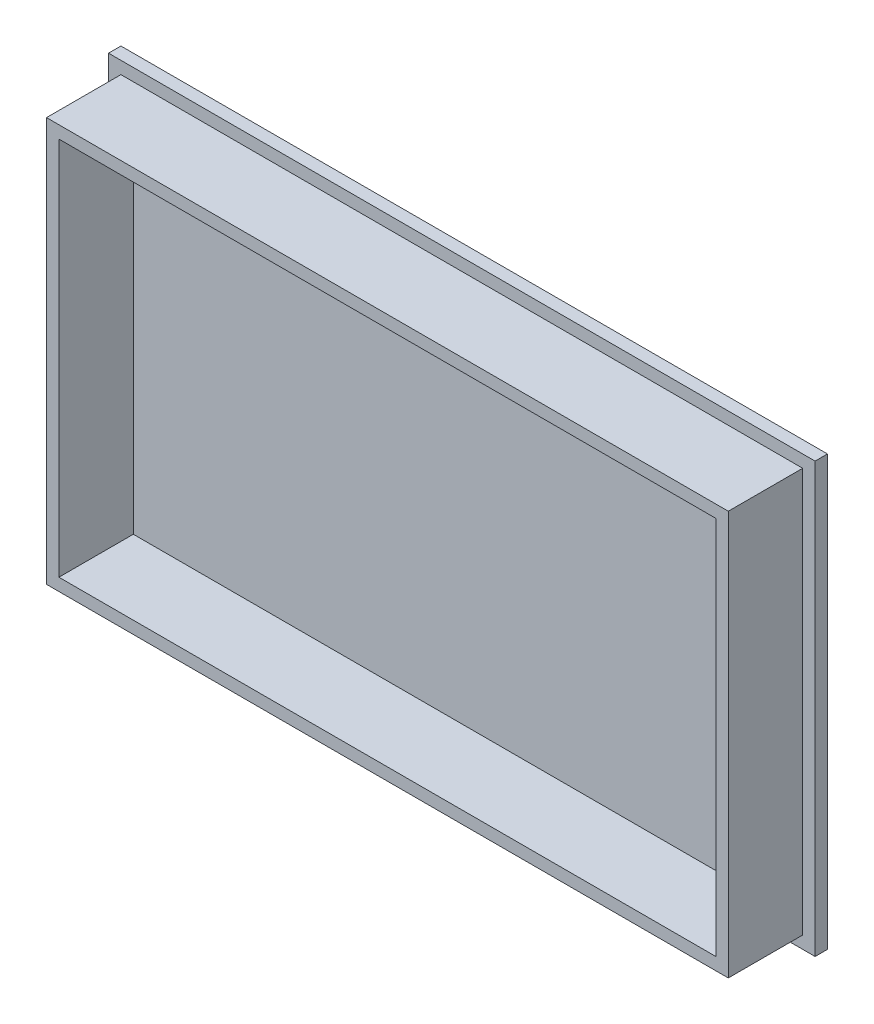
from build123d import *

# Parameters (mm, degrees)
SKETCH2_W           = 284.9
SKETCH2_H           = 173
BOSS_EXTRUDE1_DEPTH = 5
SKETCH3_W           = 274.9
SKETCH3_H           = 163
BOSS_EXTRUDE2_DEPTH = 30
SKETCH4_W           = 264.9
SKETCH4_H           = 153
CUT_EXTRUDE1_DEPTH  = 30


with BuildPart() as part:
    # Sketch2 → Boss-Extrude1 (new body)
    with BuildSketch(Plane.XY):
        with Locations((5.822942798, -16.660944206)):
            Rectangle(SKETCH2_W, SKETCH2_H)
    extrude(amount=BOSS_EXTRUDE1_DEPTH)

    # Sketch3 → Boss-Extrude2 (add)
    with BuildSketch(Plane.XY.offset(5)):
        with Locations((5.822942798, -16.660944206)):
            Rectangle(SKETCH3_W, SKETCH3_H)
    extrude(amount=BOSS_EXTRUDE2_DEPTH)

    # Sketch4 → Cut-Extrude1 (cut)
    with BuildSketch(Plane.XY.offset(35)):
        with Locations((5.822942798, -16.660944206)):
            Rectangle(SKETCH4_W, SKETCH4_H)
    extrude(amount=-CUT_EXTRUDE1_DEPTH, mode=Mode.SUBTRACT)


solid = part.part
